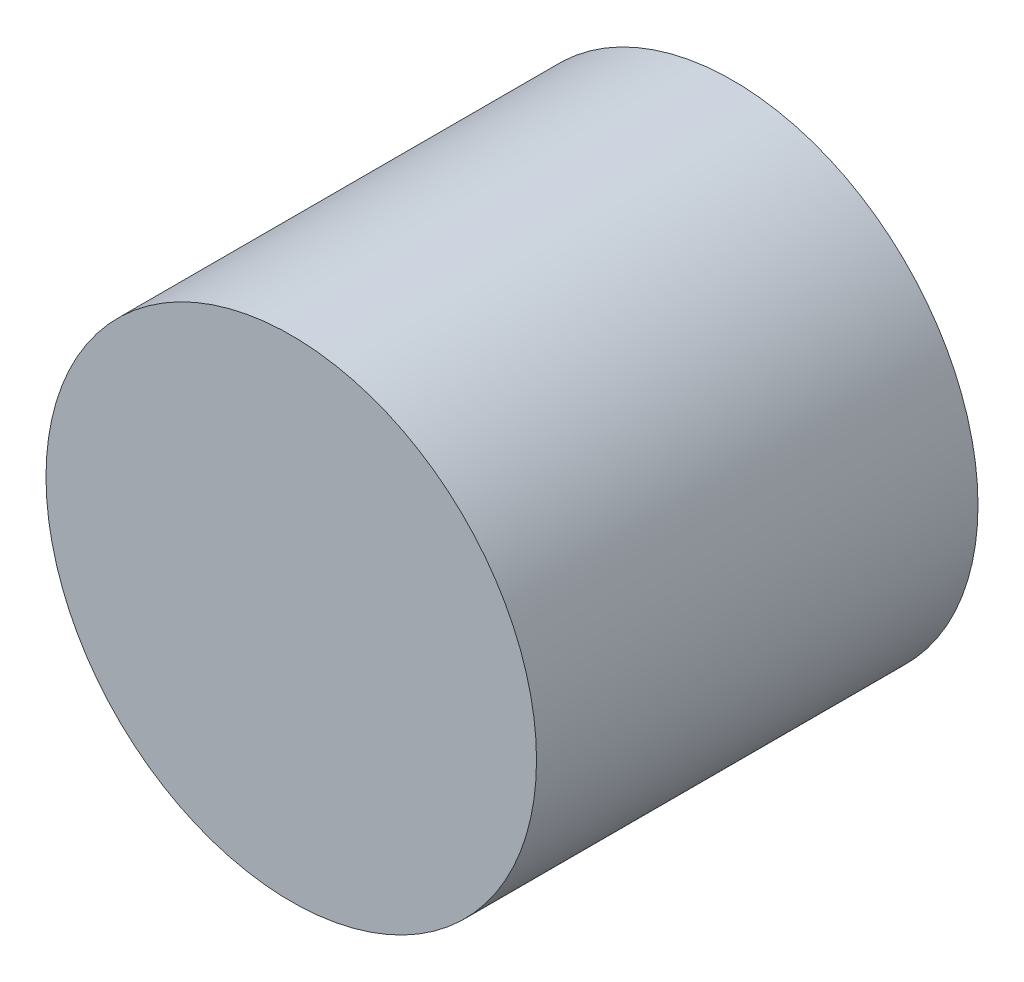
from build123d import *

# Parameters (mm, degrees)
CROQUIS1_R              = 1
SALIENTE_EXTRUIR1_DEPTH = 1.8


with BuildPart() as part:
    # Croquis1 → Saliente-Extruir1 (new body)
    with BuildSketch(Plane.XY):
        Circle(CROQUIS1_R)
    extrude(amount=SALIENTE_EXTRUIR1_DEPTH)


solid = part.part
